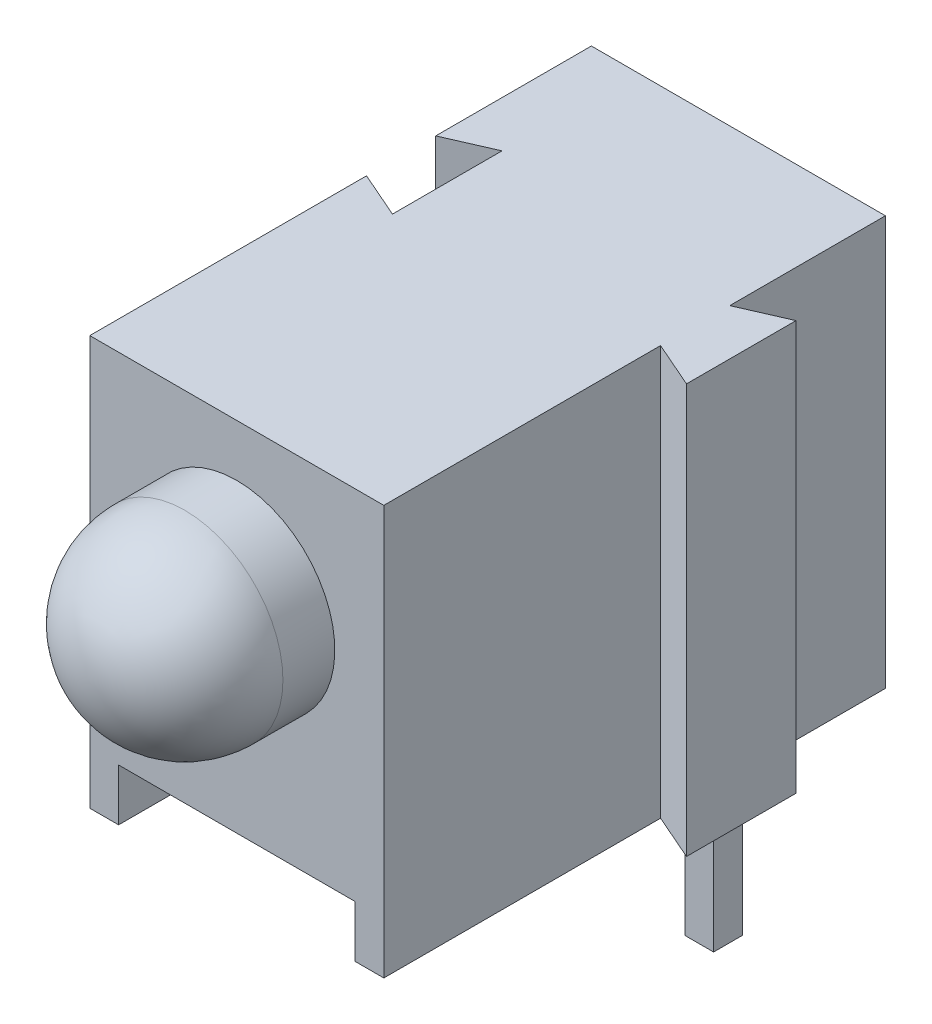
from build123d import *

# Parameters (mm, degrees)
SKETCH1_W          = 8.7
SKETCH1_H          = 7.1
EXTRUDE1_DEPTH     = 2.55
SKETCH1_5_W        = 8.7
SKETCH1_5_H        = 0.9
CUT_EXTRUDE1_DEPTH = 2.05
CUT_EXTRUDE2_DEPTH = 8.1
EXTRUDE2_DEPTH     = 7.1
SKETCH3_W          = 0.5
SKETCH3_H          = 1.45
SKETCH3_H_2        = 0.5
CUT_EXTRUDE3_DEPTH = 4.5
SKETCH3_3_W        = 0.5
SKETCH3_3_H        = 0.5
EXTRUDE3_DEPTH     = 4.5
SKETCH3_4_W        = 0.5
SKETCH3_4_H        = 0.5
EXTRUDE4_DEPTH     = 3.5
SKETCH4_W          = 0.025316456
SKETCH4_H          = 0.026582278
CUT_EXTRUDE4_DEPTH = 0.01


with BuildPart() as part:
    # Sketch1 → Extrude1 (new body, symmetric)
    with BuildSketch(Plane(origin=(0, 0, 0), x_dir=(0, 0, -1), z_dir=(1, 0, 0))):
        Rectangle(SKETCH1_W, SKETCH1_H)
    extrude(amount=EXTRUDE1_DEPTH, both=True)

    # Sketch1_3 → Revolve1 (revolve)
    with BuildSketch(Plane(origin=(0, 0, 0), x_dir=(0, 0, -1), z_dir=(1, 0, 0)), mode=Mode.PRIVATE) as revolve1_sk:
        with BuildLine():
            Line((-4.35, 0.95), (-4.35, 2.65))
            Line((-4.35, 2.65), (-5.25, 2.65))
            ThreePointArc((-5.25, 2.65), (-6.452081528, 2.152081528), (-6.95, 0.95))
            Line((-6.95, 0.95), (-4.35, 0.95))
        make_face()
    revolve(revolve1_sk.sketch.rotate(Axis((0, 0.95, 4.35), (0, 0, 1)), 180), axis=Axis((0, 0.95, 4.35), (0, 0, 1)))  # turned: the seam where the file's is

    # Sketch1_5 → Cut-Extrude1 (cut, symmetric)
    with BuildSketch(Plane(origin=(0, 0, 0), x_dir=(0, 0, -1), z_dir=(1, 0, 0))):
        with Locations((0, -3.1)):
            Rectangle(SKETCH1_5_W, SKETCH1_5_H)
    extrude(amount=CUT_EXTRUDE1_DEPTH, both=True, mode=Mode.SUBTRACT)

    # Sketch2 → Cut-Extrude2 (cut, through all)
    with BuildSketch(Plane(origin=(0, 3.55, 0), x_dir=(-1, 0, 0), z_dir=(0, 1, 0))):
        Polygon((1.75, -2), (2.55, -1.65), (2.55, -0.45), (1.75, -0.1), align=None)
    extrude(amount=-CUT_EXTRUDE2_DEPTH, mode=Mode.SUBTRACT)

    # Sketch2_3 → Extrude2 (add)
    with BuildSketch(Plane(origin=(0, 3.55, 0), x_dir=(-1, 0, 0), z_dir=(0, 1, 0))):
        Polygon((-2.55, -0.45), (-3.35, -0.1), (-3.35, -2), (-2.55, -1.65), align=None)
    extrude(amount=-EXTRUDE2_DEPTH)

    # Sketch3 → Cut-Extrude3 (cut)
    with BuildSketch(Plane.XZ.offset(3.55)):
        with Locations((1.27, -3.625)):
            Rectangle(SKETCH3_W, SKETCH3_H)
        with Locations((-1.27, -3.625)):
            Rectangle(SKETCH3_W, SKETCH3_H)
        with Locations((-1.27, -2.65)):
            Rectangle(SKETCH3_W, SKETCH3_H_2)
        with Locations((1.27, -2.65)):
            Rectangle(SKETCH3_W, SKETCH3_H_2)
    extrude(amount=-CUT_EXTRUDE3_DEPTH, mode=Mode.SUBTRACT)

    # Sketch3_3 → Extrude3 (add)
    with BuildSketch(Plane.XZ.offset(3.55)):
        with Locations((-1.27, -2.65)):
            Rectangle(SKETCH3_3_W, SKETCH3_3_H)
        with Locations((1.27, -2.65)):
            Rectangle(SKETCH3_3_W, SKETCH3_3_H)
    extrude(amount=-EXTRUDE3_DEPTH)

    # Sketch3_4 → Extrude4 (add)
    with BuildSketch(Plane.XZ.offset(3.55)):
        with Locations((1.27, -2.65)):
            Rectangle(SKETCH3_4_W, SKETCH3_4_H)
        with Locations((-1.27, -2.65)):
            Rectangle(SKETCH3_4_W, SKETCH3_4_H)
    extrude(amount=EXTRUDE4_DEPTH)

    # Sketch4 → Cut-Extrude4 (cut)
    with BuildSketch(Plane.XZ.offset(2.65)):
        Polygon((-0.572151899, -2.825316456), (-0.595609177, -2.9), (-0.620352057, -2.9), (-0.636768196, -2.849663766), (-0.652294304, -2.9), (-0.678026108, -2.9), (-0.701265823, -2.825316456), (-0.676087816, -2.825316456), (-0.663093354, -2.876799842), (-0.646677215, -2.825316456), (-0.625178006, -2.825316456), (-0.608860759, -2.876799842), (-0.596044304, -2.825316456), align=None)
        Polygon((-0.437974684, -2.825316456), (-0.461431962, -2.9), (-0.486174842, -2.9), (-0.502590981, -2.849663766), (-0.518117089, -2.9), (-0.543848892, -2.9), (-0.567088608, -2.825316456), (-0.541910601, -2.825316456), (-0.528916139, -2.876799842), (-0.5125, -2.825316456), (-0.491000791, -2.825316456), (-0.474683544, -2.876799842), (-0.461867089, -2.825316456), align=None)
        Polygon((-0.303797468, -2.825316456), (-0.327254747, -2.9), (-0.351997627, -2.9), (-0.368413766, -2.849663766), (-0.383939873, -2.9), (-0.409671677, -2.9), (-0.432911392, -2.825316456), (-0.407733386, -2.825316456), (-0.394738924, -2.876799842), (-0.378322785, -2.825316456), (-0.356823576, -2.825316456), (-0.340506329, -2.876799842), (-0.327689873, -2.825316456), align=None)
        with Locations((-0.275949367, -2.886708861)):
            Rectangle(SKETCH4_W, SKETCH4_H)
        with BuildLine():
            add(Edge.make_bspline(
                [(-0.159493671, -2.868829114), (-0.15953016, -2.870051255), (-0.159601812, -2.872451133), (-0.16021153, -2.875958712), (-0.161205016, -2.879283417), (-0.162579134, -2.882446077), (-0.164367936, -2.885424696), (-0.166577526, -2.888204973), (-0.169141939, -2.890839773), (-0.172108149, -2.893245903), (-0.175388259, -2.89545028), (-0.178985835, -2.897347279), (-0.182864539, -2.898943762), (-0.187013125, -2.900282314), (-0.191459564, -2.901270894), (-0.196177094, -2.901994839), (-0.201170512, -2.902468169), (-0.20459409, -2.902510135), (-0.206348892, -2.902531646)],
                knots=[0, 0, 0, 0, 0.907352243, 1.781736951, 2.63548328, 3.47985091, 4.336556021, 5.208523475, 6.112432747, 7.062451073, 8.040435374, 9.043840564, 10.077958095, 11.152835584, 12.277940427, 13.457536469, 14.696825396, 16, 16, 16, 16], degree=3))
            add(Edge.make_bspline(
                [(-0.206348892, -2.902531646), (-0.208367148, -2.902507574), (-0.21227633, -2.902460949), (-0.217939855, -2.90203235), (-0.223207892, -2.901386211), (-0.228103607, -2.900419669), (-0.232708206, -2.899218904), (-0.237141474, -2.897927612), (-0.241422786, -2.896463197), (-0.244195876, -2.895363039), (-0.24556962, -2.894818038)],
                knots=[0, 0, 0, 0, 1.203215828, 2.33052265, 3.384689099, 4.366106119, 5.303329643, 6.221311756, 7.118865988, 8, 8, 8, 8], degree=3))
            Line((-0.24556962, -2.894818038), (-0.24556962, -2.870886076))
            Line((-0.24556962, -2.870886076), (-0.242721519, -2.870886076))
            add(Edge.make_bspline(
                [(-0.242721519, -2.870886076), (-0.241356205, -2.871967531), (-0.238633592, -2.874124092), (-0.234200359, -2.876886697), (-0.229552713, -2.87928886), (-0.224707243, -2.881262862), (-0.219810398, -2.882849186), (-0.21493502, -2.883942713), (-0.210169433, -2.884690062), (-0.207010864, -2.884770569), (-0.205458861, -2.884810127)],
                knots=[0, 0, 0, 0, 1.030622468, 2.055194264, 3.087043286, 4.125157485, 5.149848264, 6.130935704, 7.081611712, 8, 8, 8, 8], degree=3))
            add(Edge.make_bspline(
                [(-0.205458861, -2.884810127), (-0.205030085, -2.884809203), (-0.204112108, -2.884807226), (-0.202650581, -2.884679498), (-0.20099877, -2.884583922), (-0.199226261, -2.884376738), (-0.197429535, -2.884154877), (-0.195767134, -2.883779952), (-0.194257539, -2.883415085), (-0.193351018, -2.883047087), (-0.192919304, -2.882871835)],
                knots=[0, 0, 0, 0, 0.806402781, 1.726445712, 2.758724871, 3.919014682, 5.083870887, 6.16165551, 7.124521387, 8, 8, 8, 8], degree=3))
            add(Edge.make_bspline(
                [(-0.192919304, -2.882871835), (-0.192439741, -2.882643694), (-0.191497298, -2.882195346), (-0.190203698, -2.881385028), (-0.189036018, -2.880501563), (-0.187978647, -2.879536632), (-0.187104366, -2.878370882), (-0.186480499, -2.876962209), (-0.186135606, -2.875313191), (-0.186096583, -2.874137988), (-0.186075949, -2.873516614)],
                knots=[0, 0, 0, 0, 1.024747072, 2.013846092, 2.940605744, 3.850156746, 4.769278501, 5.73222711, 6.800942666, 8, 8, 8, 8], degree=3))
            add(Edge.make_bspline(
                [(-0.186075949, -2.873516614), (-0.186107794, -2.872970977), (-0.18617041, -2.871898093), (-0.186747603, -2.870362978), (-0.187657041, -2.86895381), (-0.188938631, -2.867685035), (-0.190531807, -2.866535502), (-0.192474191, -2.865553196), (-0.194724312, -2.864680009), (-0.196368382, -2.864262031), (-0.197231013, -2.864042722)],
                knots=[0, 0, 0, 0, 0.82557554, 1.623324704, 2.456147571, 3.35491006, 4.343819762, 5.427079081, 6.650009487, 8, 8, 8, 8], degree=3))
            add(Edge.make_bspline(
                [(-0.197231013, -2.864042722), (-0.199199639, -2.863594481), (-0.203238649, -2.862674831), (-0.209388473, -2.861536077), (-0.215516824, -2.860261217), (-0.219469591, -2.859054574), (-0.221400316, -2.85846519)],
                knots=[0, 0, 0, 0, 0.976100998, 2.002656142, 3.024398856, 4, 4, 4, 4], degree=3))
            add(Edge.make_bspline(
                [(-0.221400316, -2.85846519), (-0.222438835, -2.8581122), (-0.224460408, -2.857425072), (-0.227351919, -2.856263412), (-0.230013147, -2.854993582), (-0.23245286, -2.853638027), (-0.234653549, -2.852165487), (-0.236647817, -2.85062411), (-0.238410933, -2.84898407), (-0.239957738, -2.847244304), (-0.241282641, -2.845393601), (-0.242435025, -2.843448403), (-0.243417646, -2.841392984), (-0.244195684, -2.839222761), (-0.244820323, -2.836949105), (-0.245239305, -2.834571393), (-0.245538322, -2.832088264), (-0.245559046, -2.830393879), (-0.24556962, -2.829529272)],
                knots=[0, 0, 0, 0, 1.287047841, 2.5053592, 3.654260482, 4.74538952, 5.777514103, 6.75871007, 7.700244599, 8.599107454, 9.48590269, 10.366941872, 11.24940663, 12.154970331, 13.068988358, 14.012872203, 14.986013017, 16, 16, 16, 16], degree=3))
            add(Edge.make_bspline(
                [(-0.24556962, -2.829529272), (-0.245532318, -2.828373127), (-0.245458909, -2.826097855), (-0.24485748, -2.822768811), (-0.24383089, -2.819620074), (-0.242444827, -2.816616611), (-0.240616199, -2.813803525), (-0.238431404, -2.811124978), (-0.235807357, -2.808653386), (-0.232830235, -2.806353053), (-0.229542851, -2.804273654), (-0.226003867, -2.802443098), (-0.222234578, -2.800906446), (-0.218249032, -2.799632552), (-0.214030563, -2.798677881), (-0.20959333, -2.79795895), (-0.204919541, -2.797545768), (-0.20172812, -2.797494518), (-0.200098892, -2.797468354)],
                knots=[0, 0, 0, 0, 0.894990994, 1.761326291, 2.609044902, 3.454222546, 4.315366365, 5.200560057, 6.125081389, 7.100429509, 8.110379559, 9.133447974, 10.182136699, 11.259192205, 12.370181258, 13.528580438, 14.738335141, 16, 16, 16, 16], degree=3))
            add(Edge.make_bspline(
                [(-0.200098892, -2.797468354), (-0.198430198, -2.797490507), (-0.19509564, -2.797534775), (-0.1901143, -2.797913332), (-0.185159872, -2.798465644), (-0.180297448, -2.799314884), (-0.175605285, -2.800283116), (-0.17118617, -2.801382389), (-0.167106618, -2.802619896), (-0.164532965, -2.803574297), (-0.163291139, -2.80403481)],
                knots=[0, 0, 0, 0, 1.065407564, 2.129008667, 3.188544425, 4.247469455, 5.279542408, 6.247502114, 7.154394069, 8, 8, 8, 8], degree=3))
            Line((-0.163291139, -2.80403481), (-0.163291139, -2.826582278))
            Line((-0.163291139, -2.826582278), (-0.166119462, -2.826582278))
            add(Edge.make_bspline(
                [(-0.166119462, -2.826582278), (-0.167192966, -2.825782991), (-0.169383743, -2.824151825), (-0.173033347, -2.82205009), (-0.177000967, -2.820109998), (-0.181282594, -2.818418341), (-0.185742374, -2.816960334), (-0.190325133, -2.815940776), (-0.194951348, -2.815299069), (-0.198053052, -2.81522628), (-0.19960443, -2.815189873)],
                knots=[0, 0, 0, 0, 0.892265782, 1.820912499, 2.804518821, 3.836954028, 4.889985052, 5.931488012, 6.965393252, 8, 8, 8, 8], degree=3))
            add(Edge.make_bspline(
                [(-0.19960443, -2.815189873), (-0.200700035, -2.815211776), (-0.202897679, -2.81525571), (-0.20616687, -2.815640596), (-0.209407348, -2.816279448), (-0.21144203, -2.8170955), (-0.212460443, -2.817503956)],
                knots=[0, 0, 0, 0, 0.999122297, 2.004111588, 3.001004448, 4, 4, 4, 4], degree=3))
            add(Edge.make_bspline(
                [(-0.212460443, -2.817503956), (-0.212894173, -2.817705135), (-0.213761342, -2.818107359), (-0.214968884, -2.818886984), (-0.216089856, -2.819803327), (-0.217085439, -2.820856084), (-0.217929873, -2.822024438), (-0.218548899, -2.823292021), (-0.218923392, -2.824655902), (-0.218965739, -2.825591001), (-0.218987342, -2.826068038)],
                knots=[0, 0, 0, 0, 1.004925302, 2.009180302, 3.014392739, 4.04465309, 5.049195417, 6.035570224, 6.99785458, 8, 8, 8, 8], degree=3))
            add(Edge.make_bspline(
                [(-0.218987342, -2.826068038), (-0.218952904, -2.826706203), (-0.218887095, -2.827925679), (-0.218280511, -2.829641475), (-0.217295678, -2.831119909), (-0.216135073, -2.832114829), (-0.215017943, -2.832812267), (-0.213982284, -2.833322777), (-0.212773057, -2.833806136), (-0.211401809, -2.834303605), (-0.209865482, -2.834794792), (-0.208156925, -2.835270339), (-0.206274208, -2.835719635), (-0.204958333, -2.836005825), (-0.204272152, -2.836155063)],
                knots=[0, 0, 0, 0, 1.173816843, 2.243057204, 3.312297565, 4.415174738, 5.03266065, 5.73970059, 6.541434878, 7.433956553, 8.430083051, 9.515931566, 10.70464786, 12, 12, 12, 12], degree=3))
            add(Edge.make_bspline(
                [(-0.204272152, -2.836155063), (-0.202439229, -2.836530508), (-0.198844263, -2.837266879), (-0.193445039, -2.838379244), (-0.187940051, -2.839644603), (-0.184268899, -2.840796599), (-0.182357595, -2.841396361)],
                knots=[0, 0, 0, 0, 0.995749986, 1.952994291, 2.934271555, 4, 4, 4, 4], degree=3))
            add(Edge.make_bspline(
                [(-0.182357595, -2.841396361), (-0.181411107, -2.84171572), (-0.179559623, -2.842340437), (-0.176918075, -2.843425121), (-0.174469022, -2.844607211), (-0.172190751, -2.845829697), (-0.17012867, -2.847192913), (-0.168235447, -2.848607561), (-0.166552428, -2.85013567), (-0.165054478, -2.851748528), (-0.163736077, -2.85345896), (-0.162601114, -2.855297062), (-0.161637968, -2.857251591), (-0.160829836, -2.859324663), (-0.16025182, -2.861531731), (-0.159817762, -2.863858032), (-0.15952694, -2.866303347), (-0.159504884, -2.867977794), (-0.159493671, -2.868829114)],
                knots=[0, 0, 0, 0, 1.237386967, 2.420528625, 3.534815053, 4.605870898, 5.620827102, 6.594482803, 7.531295079, 8.432978826, 9.318460435, 10.202471551, 11.10474705, 12.014900263, 12.954095338, 13.926516828, 14.945802342, 16, 16, 16, 16], degree=3))
        make_face()
        with BuildLine():
            Line((-0.067088608, -2.9), (-0.091139241, -2.9))
            Line((-0.091139241, -2.9), (-0.091139241, -2.892167722))
            add(Edge.make_bspline(
                [(-0.091139241, -2.892167722), (-0.092232496, -2.892976389), (-0.094340276, -2.894535487), (-0.097514015, -2.896614252), (-0.100542736, -2.898397414), (-0.103464337, -2.899939566), (-0.106479693, -2.901130414), (-0.109707195, -2.90195227), (-0.113209459, -2.902453389), (-0.115636434, -2.902504981), (-0.116890823, -2.902531646)],
                knots=[0, 0, 0, 0, 1.150906677, 2.218931226, 3.20955724, 4.125565256, 5.012676028, 5.946647191, 6.938718366, 8, 8, 8, 8], degree=3))
            add(Edge.make_bspline(
                [(-0.116890823, -2.902531646), (-0.117907168, -2.902508916), (-0.119886286, -2.902464656), (-0.122763616, -2.902119919), (-0.125470927, -2.901581772), (-0.127987077, -2.900775916), (-0.130352422, -2.8998018), (-0.132503941, -2.898542712), (-0.13449163, -2.897083375), (-0.136295007, -2.89540644), (-0.137885627, -2.893485478), (-0.139272677, -2.891362727), (-0.140448489, -2.889028088), (-0.141390127, -2.886476722), (-0.142145061, -2.883718277), (-0.142669038, -2.880739071), (-0.142989618, -2.877551931), (-0.143021559, -2.875356803), (-0.143037975, -2.874228639)],
                knots=[0, 0, 0, 0, 1.108935798, 2.159418225, 3.158520219, 4.116592843, 5.038730546, 5.944611115, 6.829677354, 7.725673622, 8.624842385, 9.544872214, 10.487719724, 11.471363217, 12.50822837, 13.604887271, 14.769056852, 16, 16, 16, 16], degree=3))
            Line((-0.143037975, -2.874228639), (-0.143037975, -2.825316456))
            Line((-0.143037975, -2.825316456), (-0.118987342, -2.825316456))
            Line((-0.118987342, -2.825316456), (-0.118987342, -2.86289557))
            add(Edge.make_bspline(
                [(-0.118987342, -2.86289557), (-0.118985706, -2.863812041), (-0.118982576, -2.865566256), (-0.118900237, -2.868072063), (-0.118779336, -2.870340235), (-0.118640631, -2.872382264), (-0.118387615, -2.874229015), (-0.118009906, -2.875895176), (-0.11753908, -2.877414778), (-0.117074761, -2.878321479), (-0.116851266, -2.878757911)],
                knots=[0, 0, 0, 0, 1.361401701, 2.605856924, 3.723918663, 4.735739235, 5.645738665, 6.489217889, 7.27279937, 8, 8, 8, 8], degree=3))
            add(Edge.make_bspline(
                [(-0.116851266, -2.878757911), (-0.116621226, -2.879156559), (-0.116168987, -2.879940266), (-0.115249176, -2.880947414), (-0.114173193, -2.881784321), (-0.112903555, -2.882456965), (-0.111410474, -2.882940668), (-0.109678473, -2.883287415), (-0.107692458, -2.883501239), (-0.106283538, -2.883529401), (-0.105537975, -2.883544304)],
                knots=[0, 0, 0, 0, 0.849057291, 1.669173542, 2.503217716, 3.359509317, 4.311793648, 5.394940091, 6.621469141, 8, 8, 8, 8], degree=3))
            add(Edge.make_bspline(
                [(-0.105537975, -2.883544304), (-0.10499671, -2.883526846), (-0.103883832, -2.883490953), (-0.102178621, -2.883261024), (-0.100389592, -2.882899368), (-0.097875395, -2.882240345), (-0.09469925, -2.881061166), (-0.092335111, -2.879702365), (-0.091139241, -2.879015032)],
                knots=[0, 0, 0, 0, 0.638164724, 1.312110757, 2.025558264, 2.789159289, 4.375836335, 6, 6, 6, 6], degree=3))
            Line((-0.091139241, -2.879015032), (-0.091139241, -2.825316456))
            Line((-0.091139241, -2.825316456), (-0.067088608, -2.825316456))
            Line((-0.067088608, -2.825316456), (-0.067088608, -2.9))
        make_face()
        with BuildLine():
            Line((0.030379747, -2.9), (0.006329114, -2.9))
            Line((0.006329114, -2.9), (0.006329114, -2.862420886))
            add(Edge.make_bspline(
                [(0.006329114, -2.862420886), (0.00630879, -2.860890413), (0.006268255, -2.857838), (0.005934675, -2.854081225), (0.005600966, -2.851233434), (0.005224143, -2.849397367), (0.004793956, -2.847849031), (0.00438151, -2.846963294), (0.004193038, -2.846558544)],
                knots=[0, 0, 0, 0, 1.709235885, 3.408940626, 4.211008593, 4.910095588, 5.501954032, 6, 6, 6, 6], degree=3))
            add(Edge.make_bspline(
                [(0.004193038, -2.846558544), (0.00394861, -2.846160422), (0.003469373, -2.845379847), (0.002531558, -2.844367825), (0.001434909, -2.843531611), (0.000156185, -2.842866661), (-0.001328468, -2.842380763), (-0.003041142, -2.841994104), (-0.005027113, -2.841825544), (-0.006434481, -2.841790634), (-0.007179589, -2.841772152)],
                knots=[0, 0, 0, 0, 0.860145871, 1.686437142, 2.528070002, 3.393017362, 4.331453407, 5.402595683, 6.624848233, 8, 8, 8, 8], degree=3))
            add(Edge.make_bspline(
                [(-0.007179589, -2.841772152), (-0.008311478, -2.841828732), (-0.010622712, -2.841944265), (-0.013484003, -2.842657857), (-0.015810878, -2.843470154), (-0.017656499, -2.844244391), (-0.019573028, -2.845199016), (-0.020856452, -2.84592609), (-0.021518987, -2.846301424)],
                knots=[0, 0, 0, 0, 1.338419466, 2.732951426, 3.468143565, 4.254837763, 5.099104234, 6, 6, 6, 6], degree=3))
            Line((-0.021518987, -2.846301424), (-0.021518987, -2.9))
            Line((-0.021518987, -2.9), (-0.04556962, -2.9))
            Line((-0.04556962, -2.9), (-0.04556962, -2.825316456))
            Line((-0.04556962, -2.825316456), (-0.021518987, -2.825316456))
            Line((-0.021518987, -2.825316456), (-0.021518987, -2.833148734))
            add(Edge.make_bspline(
                [(-0.021518987, -2.833148734), (-0.02046175, -2.832342296), (-0.018403774, -2.830772517), (-0.015227022, -2.828739108), (-0.01215631, -2.826929251), (-0.009101788, -2.825417117), (-0.005977291, -2.824218517), (-0.00270966, -2.823402914), (0.000707053, -2.822859966), (0.003043726, -2.822810154), (0.004232595, -2.82278481)],
                knots=[0, 0, 0, 0, 1.126064518, 2.191951536, 3.19307265, 4.144813015, 5.076393104, 6.021983703, 6.993610568, 8, 8, 8, 8], degree=3))
            add(Edge.make_bspline(
                [(0.004232595, -2.82278481), (0.005228866, -2.822810199), (0.007173765, -2.822859763), (0.010008526, -2.823169473), (0.012679947, -2.823720137), (0.015172222, -2.824517966), (0.017514838, -2.825503579), (0.019676795, -2.82673509), (0.021668821, -2.828193529), (0.02349739, -2.829854471), (0.025127571, -2.831744429), (0.026547057, -2.833860802), (0.02771848, -2.83620953), (0.028727312, -2.838756667), (0.029461537, -2.841534437), (0.029987988, -2.844525203), (0.030338418, -2.847730385), (0.030365695, -2.849946285), (0.030379747, -2.851087816)],
                knots=[0, 0, 0, 0, 1.088441561, 2.124831547, 3.110816719, 4.062969431, 4.979391633, 5.88258537, 6.774334107, 7.671621258, 8.575503974, 9.49441354, 10.447872957, 11.437639084, 12.482478955, 13.580222388, 14.753440527, 16, 16, 16, 16], degree=3))
            Line((0.030379747, -2.851087816), (0.030379747, -2.9))
        make_face()
        Polygon((0.125316456, -2.9), (0.053164557, -2.9), (0.053164557, -2.8), (0.078481013, -2.8), (0.078481013, -2.881012658), (0.125316456, -2.881012658), align=None)
        Polygon((0.212658228, -2.9), (0.140506329, -2.9), (0.140506329, -2.8), (0.212658228, -2.8), (0.212658228, -2.818987342), (0.165822785, -2.818987342), (0.165822785, -2.836708861), (0.208860759, -2.836708861), (0.208860759, -2.855696203), (0.165822785, -2.855696203), (0.165822785, -2.881012658), (0.212658228, -2.881012658), align=None)
        with BuildLine():
            add(Edge.make_bspline(
                [(0.329113924, -2.850098892), (0.329094609, -2.851246581), (0.329056357, -2.853519467), (0.328761165, -2.856884274), (0.32823514, -2.860149949), (0.327555959, -2.863334198), (0.326633453, -2.866413126), (0.325551739, -2.869420703), (0.324242093, -2.872326196), (0.322737241, -2.875127631), (0.321087768, -2.877799734), (0.319313019, -2.880319942), (0.31746724, -2.88270316), (0.315477927, -2.884898054), (0.313398746, -2.886940074), (0.311223217, -2.888830888), (0.308918153, -2.890534319), (0.30731099, -2.891557203), (0.30650712, -2.892068829)],
                knots=[0, 0, 0, 0, 1.105570398, 2.18947457, 3.250358341, 4.290584537, 5.323553275, 6.344225964, 7.367641686, 8.3905646, 9.405808457, 10.390761353, 11.358902336, 12.307789878, 13.241960776, 14.165076779, 15.082208636, 16, 16, 16, 16], degree=3))
            add(Edge.make_bspline(
                [(0.30650712, -2.892068829), (0.305267899, -2.892780999), (0.302783134, -2.894208972), (0.298799188, -2.895877103), (0.294668069, -2.89728506), (0.290309515, -2.898333249), (0.285663167, -2.899061982), (0.28066851, -2.899625033), (0.275267382, -2.899925397), (0.2715325, -2.899974566), (0.269600475, -2.9)],
                knots=[0, 0, 0, 0, 0.896298978, 1.797171328, 2.70531317, 3.633678302, 4.606491125, 5.655688921, 6.787306437, 8, 8, 8, 8], degree=3))
            Line((0.269600475, -2.9), (0.234177215, -2.9))
            Line((0.234177215, -2.9), (0.234177215, -2.8))
            Line((0.234177215, -2.8), (0.270609177, -2.8))
            add(Edge.make_bspline(
                [(0.270609177, -2.8), (0.272587901, -2.800016695), (0.276404614, -2.800048899), (0.281915032, -2.800464867), (0.287013411, -2.801064387), (0.291697991, -2.801991079), (0.296006397, -2.80309973), (0.299937419, -2.804462766), (0.303549308, -2.805961038), (0.305728136, -2.807234785), (0.306784019, -2.807852057)],
                knots=[0, 0, 0, 0, 1.267192274, 2.444256634, 3.537982003, 4.553396635, 5.500903572, 6.385021601, 7.217363933, 8, 8, 8, 8], degree=3))
            add(Edge.make_bspline(
                [(0.306784019, -2.807852057), (0.307634972, -2.808388598), (0.309327097, -2.809455511), (0.311728312, -2.811237363), (0.313957739, -2.81319344), (0.316086242, -2.815245259), (0.318066056, -2.817448147), (0.319909269, -2.81978685), (0.321613036, -2.822264957), (0.323171192, -2.824874377), (0.324591277, -2.827604617), (0.325783356, -2.830476962), (0.326822718, -2.833459835), (0.327668801, -2.836558775), (0.32832513, -2.839776165), (0.328771214, -2.843113645), (0.329054647, -2.846566833), (0.329093999, -2.848911627), (0.329113924, -2.850098892)],
                knots=[0, 0, 0, 0, 0.964043478, 1.917004671, 2.862223898, 3.805158963, 4.749279098, 5.698713747, 6.657523689, 7.629652222, 8.610369353, 9.604453025, 10.607693792, 11.636365947, 12.681120053, 13.752669011, 14.862083412, 16, 16, 16, 16], degree=3))
        make_face()
        with BuildLine():
            add(Edge.make_bspline(
                [(0.302531646, -2.849940665), (0.302521175, -2.849135951), (0.302500636, -2.847557459), (0.302312313, -2.845241284), (0.302041725, -2.843015234), (0.301652591, -2.840871601), (0.301112159, -2.838821454), (0.300479977, -2.836859884), (0.299752887, -2.834980961), (0.298871957, -2.833203302), (0.297898133, -2.831494964), (0.296750689, -2.829909437), (0.295502338, -2.828396554), (0.294124055, -2.826968569), (0.292581114, -2.825662673), (0.290921012, -2.824432597), (0.289120654, -2.823304271), (0.287847665, -2.822644221), (0.287203323, -2.822310127)],
                knots=[0, 0, 0, 0, 1.152052275, 2.259818351, 3.325348653, 4.362224493, 5.376551665, 6.358740615, 7.312387502, 8.258104984, 9.197203025, 10.124507262, 11.056413058, 12.004389423, 12.961766972, 13.947352551, 14.961020569, 16, 16, 16, 16], degree=3))
            add(Edge.make_bspline(
                [(0.287203323, -2.822310127), (0.286528425, -2.822003415), (0.285190731, -2.82139549), (0.283119908, -2.820664298), (0.281030524, -2.820091462), (0.278828925, -2.819660604), (0.276359165, -2.819338673), (0.273433583, -2.819141415), (0.269977674, -2.818999245), (0.267490959, -2.818991494), (0.266159019, -2.818987342)],
                knots=[0, 0, 0, 0, 0.826967603, 1.639107464, 2.447640171, 3.242670507, 4.14065217, 5.225198036, 6.513753944, 8, 8, 8, 8], degree=3))
            Line((0.266159019, -2.818987342), (0.259493671, -2.818987342))
            Line((0.259493671, -2.818987342), (0.259493671, -2.881012658))
            Line((0.259493671, -2.881012658), (0.266159019, -2.881012658))
            add(Edge.make_bspline(
                [(0.266159019, -2.881012658), (0.266917226, -2.881007912), (0.268380993, -2.88099875), (0.27049723, -2.880955637), (0.272463046, -2.880908923), (0.274267852, -2.880791885), (0.275920195, -2.880721386), (0.277406342, -2.880537715), (0.278743292, -2.88040324), (0.280315773, -2.880125517), (0.28217096, -2.879719542), (0.284337749, -2.879036384), (0.286478448, -2.87818681), (0.287866999, -2.877501731), (0.288568038, -2.877155854)],
                knots=[0, 0, 0, 0, 1.186805873, 2.291202465, 3.313317863, 4.264127762, 5.122212376, 5.900577546, 6.607154111, 7.224697658, 8.398873738, 9.57716935, 10.776782771, 12, 12, 12, 12], degree=3))
            add(Edge.make_bspline(
                [(0.288568038, -2.877155854), (0.289153152, -2.876814337), (0.290307072, -2.876140819), (0.291930612, -2.875006768), (0.293438202, -2.873798958), (0.294834679, -2.872510818), (0.296096265, -2.871121432), (0.297252353, -2.869661966), (0.29825774, -2.868101645), (0.299496994, -2.865912819), (0.300744084, -2.862888062), (0.301776483, -2.858915308), (0.302415631, -2.854556396), (0.302491983, -2.851518655), (0.302531646, -2.849940665)],
                knots=[0, 0, 0, 0, 0.755237594, 1.489427721, 2.205882609, 2.908165467, 3.605466573, 4.296695275, 4.981837198, 5.673065901, 7.099889822, 8.61390339, 10.241051878, 12, 12, 12, 12], degree=3))
        make_face(mode=Mode.SUBTRACT)
        with Locations((0.360759494, -2.886708861)):
            Rectangle(SKETCH4_W, SKETCH4_H)
        with BuildLine():
            add(Edge.make_bspline(
                [(0.435403481, -2.902531646), (0.433813364, -2.902509842), (0.43069222, -2.902467046), (0.426120933, -2.901990018), (0.421755567, -2.901272721), (0.417609943, -2.900250402), (0.4136994, -2.898909883), (0.41004445, -2.897239877), (0.406627778, -2.895272681), (0.404565858, -2.893687785), (0.403540348, -2.892899525)],
                knots=[0, 0, 0, 0, 1.123701398, 2.205645569, 3.245398653, 4.249180969, 5.220497262, 6.163202923, 7.086456062, 8, 8, 8, 8], degree=3))
            add(Edge.make_bspline(
                [(0.403540348, -2.892899525), (0.402588713, -2.892044692), (0.400689124, -2.890338332), (0.398221497, -2.887367788), (0.396103421, -2.884078815), (0.394291165, -2.880487163), (0.392859214, -2.876567277), (0.391866679, -2.872317383), (0.391239075, -2.867760053), (0.391173123, -2.864611849), (0.391139241, -2.862994462)],
                knots=[0, 0, 0, 0, 0.916342154, 1.829140869, 2.758848968, 3.716597128, 4.708179637, 5.743612459, 6.840783343, 8, 8, 8, 8], degree=3))
            add(Edge.make_bspline(
                [(0.391139241, -2.862994462), (0.391178001, -2.861291235), (0.391253124, -2.857990155), (0.391916883, -2.853217967), (0.392986496, -2.848800287), (0.394524054, -2.844748378), (0.396454496, -2.841055187), (0.398718989, -2.837683352), (0.401339514, -2.834640428), (0.403346653, -2.832894988), (0.404351266, -2.832021361)],
                knots=[0, 0, 0, 0, 1.171797512, 2.271099083, 3.308930235, 4.294129479, 5.24602549, 6.17106565, 7.084581485, 8, 8, 8, 8], degree=3))
            add(Edge.make_bspline(
                [(0.404351266, -2.832021361), (0.40537705, -2.831252582), (0.407441008, -2.829705739), (0.410840547, -2.827810926), (0.41445276, -2.826206409), (0.418283877, -2.824960523), (0.422264395, -2.824011986), (0.426329936, -2.823285014), (0.430476303, -2.822864989), (0.433266488, -2.822811665), (0.434671677, -2.82278481)],
                knots=[0, 0, 0, 0, 0.952097844, 1.915695341, 2.885641886, 3.886921822, 4.905719434, 5.925883802, 6.95543633, 8, 8, 8, 8], degree=3))
            add(Edge.make_bspline(
                [(0.434671677, -2.82278481), (0.435918404, -2.822801774), (0.438369891, -2.82283513), (0.441970824, -2.823157787), (0.445419409, -2.823687952), (0.448716721, -2.824431546), (0.451889869, -2.825324345), (0.454949341, -2.826355625), (0.457914157, -2.827493566), (0.459814835, -2.828377782), (0.460759494, -2.828817247)],
                knots=[0, 0, 0, 0, 1.107671842, 2.178058178, 3.209662749, 4.206063564, 5.179815947, 6.137646632, 7.07438927, 8, 8, 8, 8], degree=3))
            Line((0.460759494, -2.828817247), (0.460759494, -2.849367089))
            Line((0.460759494, -2.849367089), (0.45741693, -2.849367089))
            add(Edge.make_bspline(
                [(0.45741693, -2.849367089), (0.456918162, -2.848948862), (0.455836226, -2.848041638), (0.454034874, -2.846640625), (0.451901363, -2.845090059), (0.450250156, -2.844204056), (0.449367089, -2.843730222)],
                knots=[0, 0, 0, 0, 0.792878214, 1.719922066, 2.780612869, 4, 4, 4, 4], degree=3))
            add(Edge.make_bspline(
                [(0.449367089, -2.843730222), (0.448439429, -2.843287353), (0.4465324, -2.84237693), (0.443972423, -2.841557386), (0.441783392, -2.840978849), (0.439971509, -2.84072604), (0.438038089, -2.840535691), (0.436702818, -2.840516296), (0.436016614, -2.840506329)],
                knots=[0, 0, 0, 0, 1.33256682, 2.739414054, 3.480190821, 4.267897792, 5.109861573, 6, 6, 6, 6], degree=3))
            add(Edge.make_bspline(
                [(0.436016614, -2.840506329), (0.435251065, -2.840525889), (0.433767468, -2.840563794), (0.431605865, -2.840840716), (0.429587789, -2.841319451), (0.427683381, -2.841957862), (0.425944635, -2.842854102), (0.424302105, -2.84386637), (0.422827629, -2.845120877), (0.421485682, -2.846538618), (0.420298198, -2.848129131), (0.419271446, -2.849855619), (0.418388719, -2.851713512), (0.417686826, -2.85371142), (0.417129316, -2.855841282), (0.416739751, -2.858104092), (0.416497972, -2.86050369), (0.416470029, -2.862149985), (0.416455696, -2.862994462)],
                knots=[0, 0, 0, 0, 1.087094245, 2.106738054, 3.087824582, 4.029427112, 4.95060567, 5.859714611, 6.763601524, 7.690850518, 8.627131371, 9.576106403, 10.539384251, 11.543302637, 12.578856349, 13.662518017, 14.800975475, 16, 16, 16, 16], degree=3))
            add(Edge.make_bspline(
                [(0.416455696, -2.862994462), (0.416470471, -2.863858618), (0.416499177, -2.865537631), (0.416732691, -2.867979242), (0.417148582, -2.870260673), (0.41771983, -2.872385993), (0.418444178, -2.874352011), (0.419349295, -2.876149408), (0.420385652, -2.877806215), (0.42163021, -2.879268827), (0.422994093, -2.880585149), (0.424508985, -2.881721283), (0.426168224, -2.882669428), (0.427950405, -2.883473891), (0.429883445, -2.884052289), (0.431939982, -2.884488981), (0.434129537, -2.884777538), (0.435639891, -2.884799101), (0.436412184, -2.884810127)],
                knots=[0, 0, 0, 0, 1.230336593, 2.390482092, 3.487897344, 4.52859895, 5.520747884, 6.465347575, 7.38981449, 8.296085817, 9.192433006, 10.084246191, 10.984321635, 11.908883871, 12.862027947, 13.850751296, 14.901019963, 16, 16, 16, 16], degree=3))
            add(Edge.make_bspline(
                [(0.436412184, -2.884810127), (0.437138026, -2.884801903), (0.438553028, -2.884785872), (0.440611451, -2.884569805), (0.442565368, -2.884290479), (0.444399915, -2.883849202), (0.446104164, -2.883314318), (0.447669817, -2.882743492), (0.449082423, -2.882139212), (0.449943758, -2.881671596), (0.450356013, -2.881447785)],
                knots=[0, 0, 0, 0, 1.200879421, 2.341068892, 3.423000803, 4.465923194, 5.460027553, 6.378409259, 7.223869634, 8, 8, 8, 8], degree=3))
            add(Edge.make_bspline(
                [(0.450356013, -2.881447785), (0.451064369, -2.881020099), (0.452425742, -2.88019814), (0.454250861, -2.87877768), (0.455894986, -2.87737124), (0.456919091, -2.876414472), (0.45741693, -2.875949367)],
                knots=[0, 0, 0, 0, 1.105932972, 2.12546697, 3.088749538, 4, 4, 4, 4], degree=3))
            Line((0.45741693, -2.875949367), (0.460759494, -2.875949367))
            Line((0.460759494, -2.875949367), (0.460759494, -2.896657437))
            add(Edge.make_bspline(
                [(0.460759494, -2.896657437), (0.459814117, -2.897094979), (0.457923136, -2.897970168), (0.455008359, -2.899123319), (0.452015116, -2.900096198), (0.448963886, -2.900988545), (0.445794254, -2.90168674), (0.442476905, -2.90217597), (0.438995601, -2.902477709), (0.436617185, -2.902513421), (0.435403481, -2.902531646)],
                knots=[0, 0, 0, 0, 0.952024047, 1.90427691, 2.862762905, 3.827874523, 4.80891974, 5.826446878, 6.890837857, 8, 8, 8, 8], degree=3))
        make_face()
        with BuildLine():
            add(Edge.make_bspline(
                [(0.553164557, -2.862697785), (0.553139637, -2.864202617), (0.553091062, -2.867135938), (0.552554854, -2.871408758), (0.551731391, -2.875439199), (0.550598066, -2.879240037), (0.549080213, -2.882783083), (0.547237799, -2.886079037), (0.545064208, -2.889131219), (0.542573889, -2.891921446), (0.539772404, -2.894419638), (0.536698638, -2.896615831), (0.533328772, -2.898422879), (0.529720026, -2.899949428), (0.525830719, -2.901105529), (0.521671624, -2.90192348), (0.517254115, -2.902457811), (0.514215749, -2.902506624), (0.512658228, -2.902531646)],
                knots=[0, 0, 0, 0, 1.120122129, 2.18341868, 3.201215738, 4.181270334, 5.131540819, 6.065757527, 6.988093576, 7.916512302, 8.844931028, 9.778115023, 10.722851943, 11.686686084, 12.691660064, 13.738321946, 14.84062285, 16, 16, 16, 16], degree=3))
            add(Edge.make_bspline(
                [(0.512658228, -2.902531646), (0.51110068, -2.902506706), (0.508062261, -2.902458054), (0.503645127, -2.901922584), (0.499490907, -2.901109866), (0.495606256, -2.899940631), (0.491991945, -2.898428541), (0.488618118, -2.896615099), (0.485543936, -2.894419846), (0.482742733, -2.891921336), (0.480251696, -2.889131451), (0.478080692, -2.886078221), (0.476229753, -2.882788429), (0.47474936, -2.879231154), (0.473576829, -2.875443946), (0.472764049, -2.871407948), (0.472224732, -2.867136157), (0.472176594, -2.864202691), (0.472151899, -2.862697785)],
                knots=[0, 0, 0, 0, 1.159424321, 2.261770074, 3.308474541, 4.308788811, 5.277191138, 6.221966496, 7.15518846, 8.08364496, 9.01210146, 9.934475036, 10.868729753, 11.817121636, 12.798654016, 13.816492484, 14.879832297, 16, 16, 16, 16], degree=3))
            add(Edge.make_bspline(
                [(0.472151899, -2.862697785), (0.472177022, -2.861186361), (0.472226107, -2.858233351), (0.472761477, -2.853934478), (0.473579494, -2.849873828), (0.474739526, -2.846065514), (0.476255799, -2.842513914), (0.478096824, -2.83921181), (0.480293292, -2.836165235), (0.48280279, -2.833375483), (0.485614584, -2.830879102), (0.488708516, -2.828706197), (0.492060435, -2.826869539), (0.495667634, -2.825347706), (0.49955419, -2.824213141), (0.503691132, -2.823395562), (0.508088526, -2.82285749), (0.511107264, -2.822809478), (0.512658228, -2.82278481)],
                knots=[0, 0, 0, 0, 1.124034801, 2.196132384, 3.217834281, 4.203147447, 5.152578239, 6.085969439, 7.010345409, 7.941219594, 8.872481455, 9.802010446, 10.748267785, 11.711250247, 12.709230373, 13.754967386, 14.846549946, 16, 16, 16, 16], degree=3))
            add(Edge.make_bspline(
                [(0.512658228, -2.82278481), (0.514228972, -2.822809522), (0.517287148, -2.822857636), (0.521730477, -2.823393975), (0.525904607, -2.824206501), (0.529802216, -2.825374571), (0.533426224, -2.82687784), (0.5367734, -2.828732787), (0.539858359, -2.830907137), (0.542626621, -2.833436965), (0.54511038, -2.836231919), (0.547272736, -2.839289599), (0.549108213, -2.842597175), (0.550583955, -2.846159051), (0.551758158, -2.849951683), (0.552578569, -2.853986109), (0.553084721, -2.858261016), (0.553137483, -2.861193159), (0.553164557, -2.862697785)],
                knots=[0, 0, 0, 0, 1.167473013, 2.273023816, 3.322954552, 4.326451713, 5.293391623, 6.234801871, 7.166614545, 8.093305908, 9.017100806, 9.942078766, 10.872536262, 11.824015763, 12.804065898, 13.820367293, 14.881523901, 16, 16, 16, 16], degree=3))
        make_face()
        with BuildLine():
            add(Edge.make_bspline(
                [(0.523457278, -2.881190665), (0.523812024, -2.880690471), (0.524533974, -2.879672519), (0.525409914, -2.877977327), (0.526169567, -2.87614606), (0.526788254, -2.874119777), (0.527298396, -2.871822), (0.527600016, -2.869165068), (0.527832831, -2.866130182), (0.527842811, -2.863977374), (0.527848101, -2.862836234)],
                knots=[0, 0, 0, 0, 0.765094823, 1.557058493, 2.376706509, 3.238810155, 4.199844458, 5.312104478, 6.575226644, 8, 8, 8, 8], degree=3))
            add(Edge.make_bspline(
                [(0.527848101, -2.862836234), (0.527830412, -2.861761353), (0.527796522, -2.859701996), (0.527610152, -2.856742233), (0.527261478, -2.854058807), (0.5267636, -2.851641411), (0.526153829, -2.849470723), (0.525427894, -2.84752836), (0.524589376, -2.845809758), (0.523903909, -2.844804527), (0.523575949, -2.844323576)],
                knots=[0, 0, 0, 0, 1.337076348, 2.561692668, 3.686680134, 4.69989255, 5.629188848, 6.488203485, 7.276684665, 8, 8, 8, 8], degree=3))
            add(Edge.make_bspline(
                [(0.523575949, -2.844323576), (0.523237376, -2.843885739), (0.522576126, -2.843030622), (0.521418372, -2.841926988), (0.520137891, -2.841049038), (0.518757044, -2.840380373), (0.517316335, -2.839866864), (0.515810213, -2.839510822), (0.514253653, -2.839289659), (0.513192974, -2.839256981), (0.512658228, -2.839240506)],
                knots=[0, 0, 0, 0, 1.058499091, 2.067300666, 3.047512573, 4.018335651, 4.996351322, 5.969796037, 6.97646375, 8, 8, 8, 8], degree=3))
            add(Edge.make_bspline(
                [(0.512658228, -2.839240506), (0.512130325, -2.839251536), (0.511097766, -2.83927311), (0.509594689, -2.839451627), (0.508179036, -2.839751626), (0.50683387, -2.840155811), (0.505548722, -2.840767188), (0.504317445, -2.841616005), (0.503102058, -2.842692585), (0.50236373, -2.84354292), (0.501977848, -2.843987342)],
                knots=[0, 0, 0, 0, 1.04189444, 2.037910168, 2.982338511, 3.896140384, 4.804271323, 5.778885192, 6.839150358, 8, 8, 8, 8], degree=3))
            add(Edge.make_bspline(
                [(0.501977848, -2.843987342), (0.501642414, -2.844461009), (0.500938424, -2.845455117), (0.500089235, -2.847175487), (0.499319936, -2.849120978), (0.498640648, -2.851312114), (0.498109463, -2.853779654), (0.497751274, -2.856538267), (0.497506594, -2.859588201), (0.497481478, -2.861721508), (0.497468354, -2.862836234)],
                knots=[0, 0, 0, 0, 0.70629823, 1.482341141, 2.329662943, 3.254583898, 4.274063958, 5.401087491, 6.641978366, 8, 8, 8, 8], degree=3))
            add(Edge.make_bspline(
                [(0.497468354, -2.862836234), (0.497474295, -2.863838973), (0.4974858, -2.865781105), (0.497727995, -2.868583437), (0.498014823, -2.871191881), (0.498501392, -2.873579934), (0.49907323, -2.87576511), (0.499821274, -2.877716704), (0.500644614, -2.879471777), (0.501344968, -2.880499516), (0.501681171, -2.88099288)],
                knots=[0, 0, 0, 0, 1.270983191, 2.461674417, 3.564986371, 4.596265355, 5.549463796, 6.425202083, 7.244022889, 8, 8, 8, 8], degree=3))
            add(Edge.make_bspline(
                [(0.501681171, -2.88099288), (0.502021533, -2.881409655), (0.502692579, -2.882231352), (0.503840375, -2.883307493), (0.505108347, -2.88418205), (0.506457966, -2.88490504), (0.507924557, -2.885439423), (0.509484843, -2.885809356), (0.511142292, -2.886028495), (0.512275179, -2.886059866), (0.512856013, -2.886075949)],
                knots=[0, 0, 0, 0, 1.010886179, 1.993025998, 2.945391046, 3.898964935, 4.863589088, 5.87059323, 6.908247091, 8, 8, 8, 8], degree=3))
            add(Edge.make_bspline(
                [(0.512856013, -2.886075949), (0.513863641, -2.886023428), (0.515861448, -2.885919295), (0.518276869, -2.885202888), (0.520078527, -2.88434791), (0.521333325, -2.883488501), (0.522471635, -2.882427732), (0.523124499, -2.881608331), (0.523457278, -2.881190665)],
                knots=[0, 0, 0, 0, 1.49343762, 2.961012893, 3.700518105, 4.446788108, 5.208294864, 6, 6, 6, 6], degree=3))
        make_face(mode=Mode.SUBTRACT)
        with BuildLine():
            Line((0.644303797, -2.846301424), (0.644303797, -2.9))
            Line((0.644303797, -2.9), (0.620253165, -2.9))
            Line((0.620253165, -2.9), (0.620253165, -2.862143987))
            add(Edge.make_bspline(
                [(0.620253165, -2.862143987), (0.620246898, -2.861253988), (0.620234875, -2.859546423), (0.620212363, -2.857086093), (0.620096991, -2.854838751), (0.620000439, -2.852791415), (0.619801755, -2.85093503), (0.619524083, -2.849255321), (0.619095228, -2.847752325), (0.618687802, -2.84685121), (0.61849288, -2.846420095)],
                knots=[0, 0, 0, 0, 1.33997484, 2.570892857, 3.703483919, 4.727540125, 5.655929516, 6.512630168, 7.288405602, 8, 8, 8, 8], degree=3))
            add(Edge.make_bspline(
                [(0.61849288, -2.846420095), (0.618282954, -2.846034728), (0.61786683, -2.845270835), (0.616998785, -2.844302974), (0.615990476, -2.843492329), (0.614810314, -2.842850874), (0.613431631, -2.842352712), (0.611816509, -2.842003366), (0.609952652, -2.841822964), (0.608630364, -2.841789727), (0.607931171, -2.841772152)],
                knots=[0, 0, 0, 0, 0.859345536, 1.703436662, 2.532498256, 3.390183975, 4.328249457, 5.402602062, 6.626559876, 8, 8, 8, 8], degree=3))
            add(Edge.make_bspline(
                [(0.607931171, -2.841772152), (0.607343832, -2.841795547), (0.606163857, -2.841842549), (0.604399742, -2.842087491), (0.602672133, -2.842582874), (0.600453045, -2.843420585), (0.597854183, -2.844644777), (0.595886252, -2.845762239), (0.594936709, -2.846301424)],
                knots=[0, 0, 0, 0, 0.759382397, 1.525614786, 2.294447385, 3.076151307, 4.589219126, 6, 6, 6, 6], degree=3))
            Line((0.594936709, -2.846301424), (0.594936709, -2.9))
            Line((0.594936709, -2.9), (0.570886076, -2.9))
            Line((0.570886076, -2.9), (0.570886076, -2.825316456))
            Line((0.570886076, -2.825316456), (0.594936709, -2.825316456))
            Line((0.594936709, -2.825316456), (0.594936709, -2.833148734))
            add(Edge.make_bspline(
                [(0.594936709, -2.833148734), (0.595957797, -2.832367354), (0.597940337, -2.830850231), (0.600953613, -2.828802903), (0.603906507, -2.827047319), (0.606799194, -2.825499423), (0.609752873, -2.824259808), (0.612851277, -2.823416869), (0.616094567, -2.822885797), (0.618312774, -2.822818882), (0.619442247, -2.82278481)],
                knots=[0, 0, 0, 0, 1.136109262, 2.205863928, 3.217041414, 4.170849475, 5.103496751, 6.040664374, 7.002340634, 8, 8, 8, 8], degree=3))
            add(Edge.make_bspline(
                [(0.619442247, -2.82278481), (0.620645481, -2.822816564), (0.62299712, -2.822878625), (0.626409162, -2.823547765), (0.629624607, -2.824552833), (0.632582226, -2.826041652), (0.635302424, -2.827883104), (0.637715584, -2.830139843), (0.639805479, -2.832807086), (0.64089703, -2.834812313), (0.641455696, -2.835838608)],
                knots=[0, 0, 0, 0, 1.065971563, 2.0833675, 3.072814207, 4.045738768, 5.009267307, 5.977487593, 6.964858173, 8, 8, 8, 8], degree=3))
            add(Edge.make_bspline(
                [(0.641455696, -2.835838608), (0.642637781, -2.834861643), (0.644941436, -2.832957727), (0.648495052, -2.830415105), (0.651974132, -2.828160548), (0.655414652, -2.826251723), (0.658815096, -2.824701169), (0.662197602, -2.823607182), (0.665544031, -2.822914818), (0.667771115, -2.822827729), (0.668868671, -2.82278481)],
                knots=[0, 0, 0, 0, 1.188147474, 2.315470194, 3.384102413, 4.399459064, 5.362307068, 6.27522031, 7.149990929, 8, 8, 8, 8], degree=3))
            add(Edge.make_bspline(
                [(0.668868671, -2.82278481), (0.669851921, -2.822808205), (0.671765063, -2.822853725), (0.67454762, -2.82318874), (0.677143805, -2.82376047), (0.679562078, -2.8245494), (0.681795216, -2.825581707), (0.683841647, -2.826858019), (0.685714647, -2.828343819), (0.687386566, -2.830065482), (0.688872492, -2.831989614), (0.690168729, -2.834124581), (0.691246883, -2.836464665), (0.692144985, -2.838999174), (0.692829098, -2.841735357), (0.693319166, -2.844678273), (0.693617377, -2.847818203), (0.693652749, -2.849979552), (0.693670886, -2.851087816)],
                knots=[0, 0, 0, 0, 1.099528869, 2.139389204, 3.128691273, 4.06836032, 4.978849901, 5.872980696, 6.759662307, 7.646067956, 8.55014577, 9.473266406, 10.433198647, 11.426668526, 12.476415665, 13.583140093, 14.760718182, 16, 16, 16, 16], degree=3))
            Line((0.693670886, -2.851087816), (0.693670886, -2.9))
            Line((0.693670886, -2.9), (0.669620253, -2.9))
            Line((0.669620253, -2.9), (0.669620253, -2.862143987))
            add(Edge.make_bspline(
                [(0.669620253, -2.862143987), (0.669614543, -2.861247371), (0.669603583, -2.859526576), (0.669573902, -2.857060222), (0.669484266, -2.854812405), (0.669403721, -2.852772514), (0.6692351, -2.85092038), (0.668948066, -2.849248731), (0.668517939, -2.847756742), (0.668126047, -2.846851818), (0.667939082, -2.846420095)],
                knots=[0, 0, 0, 0, 1.350843832, 2.592553583, 3.715618503, 4.739861077, 5.667890227, 6.515410335, 7.291728161, 8, 8, 8, 8], degree=3))
            add(Edge.make_bspline(
                [(0.667939082, -2.846420095), (0.667735705, -2.84603509), (0.667333047, -2.845272834), (0.666483935, -2.844297842), (0.665472098, -2.843487314), (0.664275171, -2.842851662), (0.662877515, -2.84235277), (0.661242699, -2.842003605), (0.659352701, -2.841822309), (0.658010647, -2.841789544), (0.657298259, -2.841772152)],
                knots=[0, 0, 0, 0, 0.84645005, 1.675850114, 2.498752818, 3.361341904, 4.304511378, 5.383432037, 6.611077598, 8, 8, 8, 8], degree=3))
            add(Edge.make_bspline(
                [(0.657298259, -2.841772152), (0.656297666, -2.841820601), (0.65427854, -2.841918369), (0.651790256, -2.84262134), (0.649774065, -2.843450982), (0.648078326, -2.844224212), (0.646237567, -2.845194633), (0.644967402, -2.845921611), (0.644303797, -2.846301424)],
                knots=[0, 0, 0, 0, 1.291070249, 2.605286939, 3.312383926, 4.109045945, 5.012060117, 6, 6, 6, 6], degree=3))
        make_face()
    extrude(amount=-CUT_EXTRUDE4_DEPTH, mode=Mode.SUBTRACT)


solid = part.part
